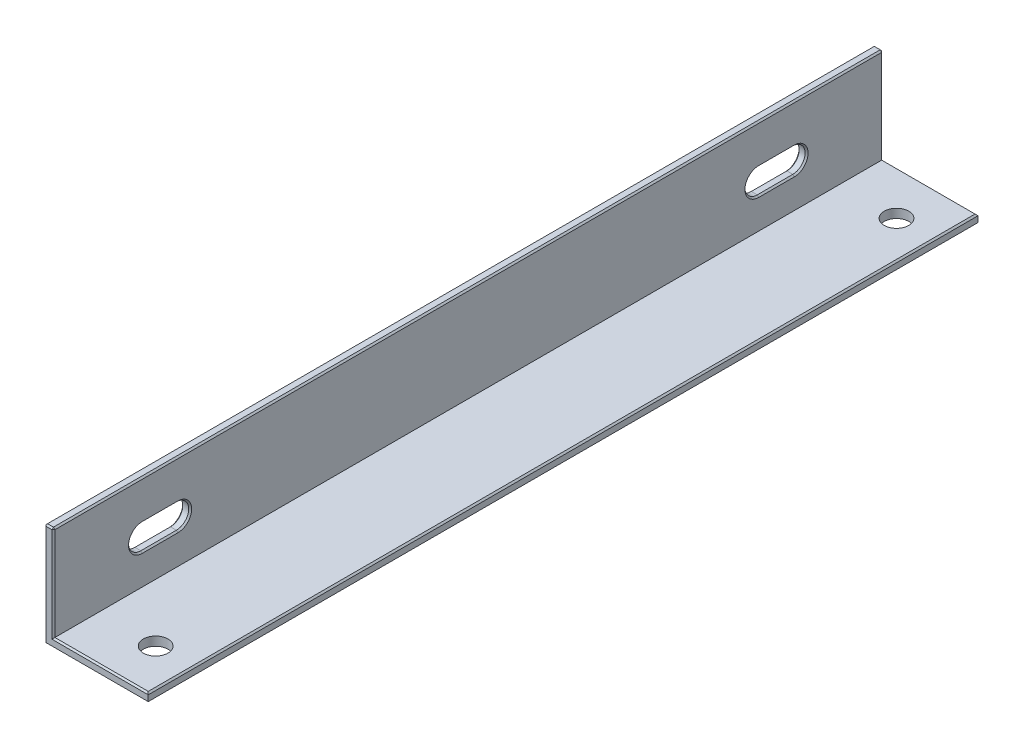
from build123d import *

# Parameters (mm, degrees)
P_IDAT_VYSUNUT_M1_DEPTH  = 280
ODEBRAT_VYSUNUT_M1_DEPTH = 4
SKICA3_R                 = 4.15
ODEBRAT_VYSUNUT_M2_DEPTH = 4
ZKOSEN_1_SIZE            = 0.5
ZKOSEN_2_SIZE            = 0.5


with BuildPart() as part:
    # Skica1 → Přidat vysunutím1 (new body)
    with BuildSketch(Plane.XY):
        Polygon((0, 35), (0, 0), (35, 0), (35, 3), (3, 3), (3, 35), align=None)
    extrude(amount=P_IDAT_VYSUNUT_M1_DEPTH)

    # Skica2 → Odebrat vysunutím1 (cut)
    with BuildSketch(Plane.ZY):
        with BuildLine():
            Line((30, 21.65), (42, 21.65))
            ThreePointArc((42, 21.65), (46.15, 17.5), (42, 13.35))
            Line((42, 13.35), (30, 13.35))
            ThreePointArc((30, 13.35), (25.85, 17.5), (30, 21.65))
        make_face()
        with BuildLine():
            Line((238, 21.65), (250, 21.65))
            ThreePointArc((250, 21.65), (254.15, 17.5), (250, 13.35))
            Line((250, 13.35), (238, 13.35))
            ThreePointArc((238, 13.35), (233.85, 17.5), (238, 21.65))
        make_face()
    extrude(amount=-ODEBRAT_VYSUNUT_M1_DEPTH, mode=Mode.SUBTRACT)

    # Skica3 → Odebrat vysunutím2 (cut)
    with BuildSketch(Plane(origin=(0, 3, 0), x_dir=(-1, 0, 0), z_dir=(0, 1, 0))):
        with Locations((-22.5, 265)):
            Circle(SKICA3_R)
        with Locations((-22.5, 15)):
            Circle(SKICA3_R)
    extrude(amount=-ODEBRAT_VYSUNUT_M2_DEPTH, mode=Mode.SUBTRACT)

    # Zkosení1
    zkosen_1_edges = [part.edges().sort_by_distance(p)[0] for p in [
        (17.5, 0, 280),
        (3, 35, 140),
        (35, 3, 140),
        (35, 0, 140),
        (19, 3, 280),
        (3, 13.35, 36),
        (3, 19, 280),
        (3, 17.5, 46.15),
        (3, 21.65, 36),
        (3, 17.5, 25.85),
        (0, 17.5, 25.85),
        (0, 13.35, 36),
        (0, 17.5, 46.15),
        (0, 21.65, 36),
        (3, 13.35, 244),
        (3, 17.5, 254.15),
        (3, 21.65, 244),
        (3, 17.5, 233.85),
        (1.5, 35, 280),
        (0, 17.5, 233.85),
        (0, 13.35, 244),
        (0, 17.5, 254.15),
        (0, 21.65, 244),
        (3, 19, 0),
        (19, 3, 0),
        (0, 17.5, 280),
        (17.5, 0, 0),
        (0, 17.5, 0),
        (1.5, 35, 0),
    ]]
    chamfer(zkosen_1_edges, length=ZKOSEN_1_SIZE)

    # Zkosení2
    zkosen_2_edges = [part.edges().sort_by_distance(p)[0] for p in [
        (0, 35, 140),
    ]]
    chamfer(zkosen_2_edges, length=ZKOSEN_2_SIZE)


solid = part.part
